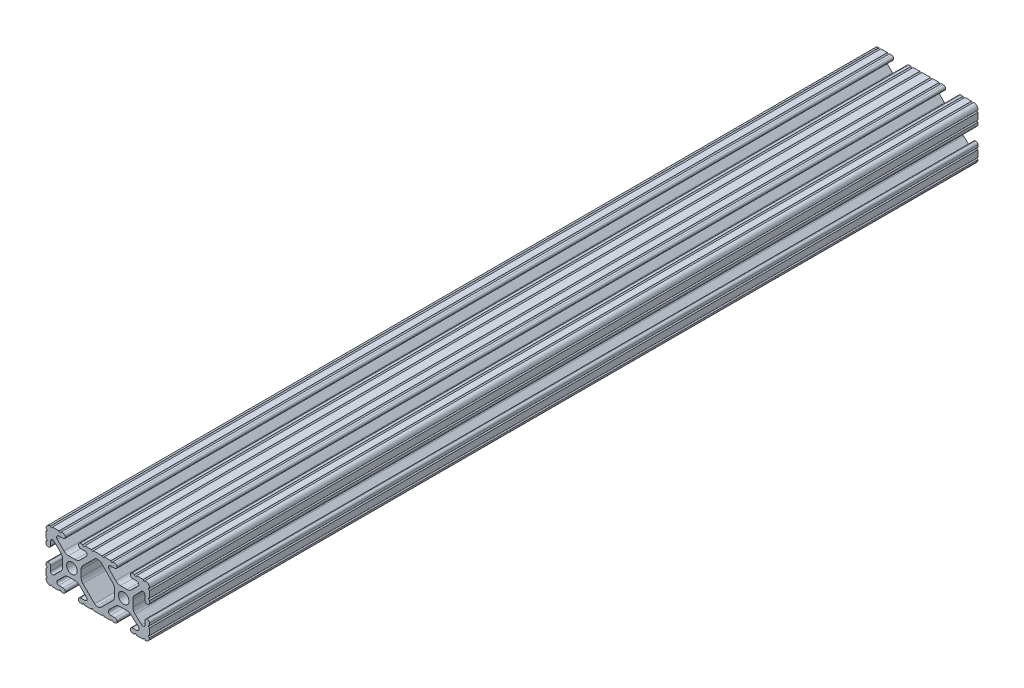
from build123d import *

# Parameters (mm, degrees)
SKETCH1_R           = 2.6035
BOSS_EXTRUDE1_DEPTH = 203.2


with BuildPart() as part:
    # Sketch1 → Boss-Extrude1 (new body, symmetric)
    with BuildSketch(Plane.XY):
        with BuildLine():
            Line((18.01710265, 12.7), (16.98745015, 12.7))
            ThreePointArc((16.98745015, 12.7), (16.245730386, 12.392769614), (15.9385, 11.65104985))
            Line((15.9385, 11.65104985), (15.9385, 11.53922))
            ThreePointArc((15.9385, 11.53922), (16.245750844, 10.797450844), (16.98752, 10.4902))
            Line((16.98752, 10.4902), (19.116384363, 10.4902))
            ThreePointArc((19.116384363, 10.4902), (20.052502933, 9.869096983), (19.844087081, 8.765172272))
            Line((19.844087081, 8.765172272), (16.618993479, 5.455112286))
            ThreePointArc((16.618993479, 5.455112286), (15.578994274, 4.745442459), (14.344932584, 4.4958))
            Line((14.344932584, 4.4958), (11.083317835, 4.4958))
            ThreePointArc((11.083317835, 4.4958), (9.854330953, 4.743306833), (8.816955189, 5.447238587))
            Line((8.816955189, 5.447238587), (5.564154119, 8.762652677))
            ThreePointArc((5.564154119, 8.762652677), (5.352591412, 9.867473037), (6.289393385, 10.4902))
            Line((6.289393385, 10.4902), (8.41248, 10.4902))
            ThreePointArc((8.41248, 10.4902), (9.154249156, 10.797450844), (9.4615, 11.53922))
            Line((9.4615, 11.53922), (9.4615, 11.65104985))
            ThreePointArc((9.4615, 11.65104985), (9.154269614, 12.392769614), (8.41254985, 12.7))
            Line((8.41254985, 12.7), (7.38288465, 12.7))
            ThreePointArc((7.38288465, 12.7), (6.87488465, 12.192), (6.36688465, 12.7))
            Line((6.36688465, 12.7), (3.14958095, 12.7))
            ThreePointArc((3.14958095, 12.7), (2.64158095, 12.192), (2.13358095, 12.7))
            Line((2.13358095, 12.7), (-2.13358095, 12.7))
            ThreePointArc((-2.13358095, 12.7), (-2.64158095, 12.192), (-3.14958095, 12.7))
            Line((-3.14958095, 12.7), (-6.36689735, 12.7))
            ThreePointArc((-6.36689735, 12.7), (-6.87489735, 12.192), (-7.38289735, 12.7))
            Line((-7.38289735, 12.7), (-8.41254985, 12.7))
            ThreePointArc((-8.41254985, 12.7), (-9.154269614, 12.392769614), (-9.4615, 11.65104985))
            Line((-9.4615, 11.65104985), (-9.4615, 11.53922))
            ThreePointArc((-9.4615, 11.53922), (-9.154249156, 10.797450844), (-8.41248, 10.4902))
            Line((-8.41248, 10.4902), (-6.283641037, 10.4902))
            ThreePointArc((-6.283641037, 10.4902), (-5.297291557, 9.829633109), (-5.532576693, 8.666071843))
            Line((-5.532576693, 8.666071843), (-8.809985098, 5.416263103))
            ThreePointArc((-8.809985098, 5.416263103), (-9.836720513, 4.734920264), (-11.045536121, 4.4958))
            Line((-11.045536121, 4.4958), (-14.354463879, 4.4958))
            ThreePointArc((-14.354463879, 4.4958), (-15.563279487, 4.734920264), (-16.590014902, 5.416263103))
            Line((-16.590014902, 5.416263103), (-19.867423307, 8.666071843))
            ThreePointArc((-19.867423307, 8.666071843), (-20.102708443, 9.829633109), (-19.116358963, 10.4902))
            Line((-19.116358963, 10.4902), (-16.98752, 10.4902))
            ThreePointArc((-16.98752, 10.4902), (-16.245750844, 10.797450844), (-15.9385, 11.53922))
            Line((-15.9385, 11.53922), (-15.9385, 11.65104985))
            ThreePointArc((-15.9385, 11.65104985), (-16.245730386, 12.392769614), (-16.98745015, 12.7))
            Line((-16.98745015, 12.7), (-18.01711535, 12.7))
            ThreePointArc((-18.01711535, 12.7), (-18.52511535, 12.192), (-19.03311535, 12.7))
            Line((-19.03311535, 12.7), (-22.2504, 12.7))
            ThreePointArc((-22.2504, 12.7), (-22.758323491, 12.192000006), (-23.266399977, 12.699846982))
            ThreePointArc((-23.266399977, 12.699846982), (-24.782522516, 12.082522516), (-25.399846982, 10.566399977))
            ThreePointArc((-25.399846982, 10.566399977), (-24.892000006, 10.058323491), (-25.4, 9.5504))
            Line((-25.4, 9.5504), (-25.4, 6.3330836))
            ThreePointArc((-25.4, 6.3330836), (-24.892, 5.8250836), (-25.4, 5.3170836))
            Line((-25.4, 5.3170836), (-25.4, 4.237520184))
            ThreePointArc((-25.4, 4.237520184), (-25.107393763, 3.531106237), (-24.400979816, 3.2385))
            Line((-24.400979816, 3.2385), (-24.23922, 3.2385))
            ThreePointArc((-24.23922, 3.2385), (-23.497450844, 3.545750844), (-23.1902, 4.28752))
            Line((-23.1902, 4.28752), (-23.1902, 6.334741132))
            ThreePointArc((-23.1902, 6.334741132), (-22.556026952, 7.286023527), (-21.434002553, 7.066535717))
            Line((-21.434002553, 7.066535717), (-18.147950853, 3.808156468))
            ThreePointArc((-18.147950853, 3.808156468), (-17.452759693, 2.774838327), (-17.208501877, 1.553619571))
            Line((-17.208501877, 1.553619571), (-17.208501877, -1.695179196))
            ThreePointArc((-17.208501877, -1.695179196), (-17.450738657, -2.911536421), (-18.140486065, -3.942289578))
            Line((-18.140486065, -3.942289578), (-21.431579576, -7.227386226))
            ThreePointArc((-21.431579576, -7.227386226), (-22.55444896, -7.449940594), (-23.1902, -6.498002195))
            Line((-23.1902, -6.498002195), (-23.1902, -4.28752))
            ThreePointArc((-23.1902, -4.28752), (-23.497450844, -3.545750844), (-24.23922, -3.2385))
            Line((-24.23922, -3.2385), (-24.35098, -3.2385))
            ThreePointArc((-24.35098, -3.2385), (-25.092749156, -3.545750844), (-25.4, -4.28752))
            Line((-25.4, -4.28752), (-25.4, -5.3171344))
            ThreePointArc((-25.4, -5.3171344), (-24.892, -5.8251344), (-25.4, -6.3331344))
            Line((-25.4, -6.3331344), (-25.4, -9.5504))
            ThreePointArc((-25.4, -9.5504), (-24.892000006, -10.058323491), (-25.399846982, -10.566399977))
            ThreePointArc((-25.399846982, -10.566399977), (-24.782522516, -12.082522516), (-23.266399977, -12.699846982))
            ThreePointArc((-23.266399977, -12.699846982), (-22.758323491, -12.192000006), (-22.2504, -12.7))
            Line((-22.2504, -12.7), (-19.03308995, -12.7))
            ThreePointArc((-19.03308995, -12.7), (-18.52508995, -12.192), (-18.01708995, -12.7))
            Line((-18.01708995, -12.7), (-16.9874692, -12.7))
            ThreePointArc((-16.9874692, -12.7), (-16.245700044, -12.392749156), (-15.9384492, -11.65098))
            Line((-15.9384492, -11.65098), (-15.9384492, -11.53922))
            ThreePointArc((-15.9384492, -11.53922), (-16.245700044, -10.797450844), (-16.9874692, -10.4902))
            Line((-16.9874692, -10.4902), (-19.116358963, -10.4902))
            ThreePointArc((-19.116358963, -10.4902), (-20.055197748, -9.862578342), (-19.834124023, -8.755124678))
            Line((-19.834124023, -8.755124678), (-16.49660751, -5.423689618))
            ThreePointArc((-16.49660751, -5.423689618), (-15.467274017, -4.736928798), (-14.253591699, -4.4958))
            Line((-14.253591699, -4.4958), (-11.146408301, -4.4958))
            ThreePointArc((-11.146408301, -4.4958), (-9.932725983, -4.736928798), (-8.90339249, -5.423689618))
            Line((-8.90339249, -5.423689618), (-5.565875977, -8.755124678))
            ThreePointArc((-5.565875977, -8.755124678), (-5.344802252, -9.862578342), (-6.283641037, -10.4902))
            Line((-6.283641037, -10.4902), (-8.4125308, -10.4902))
            ThreePointArc((-8.4125308, -10.4902), (-9.154299956, -10.797450844), (-9.4615508, -11.53922))
            Line((-9.4615508, -11.53922), (-9.4615508, -11.65098))
            ThreePointArc((-9.4615508, -11.65098), (-9.154299956, -12.392749156), (-8.4125308, -12.7))
            Line((-8.4125308, -12.7), (-7.38287195, -12.7))
            ThreePointArc((-7.38287195, -12.7), (-6.87487195, -12.192), (-6.36687195, -12.7))
            Line((-6.36687195, -12.7), (-3.14960635, -12.7))
            ThreePointArc((-3.14960635, -12.7), (-2.64160635, -12.192), (-2.13360635, -12.7))
            Line((-2.13360635, -12.7), (2.13360635, -12.7))
            ThreePointArc((2.13360635, -12.7), (2.64159365, -12.1920127), (3.14958095, -12.7))
            Line((3.14958095, -12.7), (6.36691005, -12.7))
            ThreePointArc((6.36691005, -12.7), (6.87491005, -12.192), (7.38291005, -12.7))
            Line((7.38291005, -12.7), (8.4125308, -12.7))
            ThreePointArc((8.4125308, -12.7), (9.154299956, -12.392749156), (9.4615508, -11.65098))
            Line((9.4615508, -11.65098), (9.4615508, -11.53922))
            ThreePointArc((9.4615508, -11.53922), (9.154299956, -10.797450844), (8.4125308, -10.4902))
            Line((8.4125308, -10.4902), (6.289393385, -10.4902))
            ThreePointArc((6.289393385, -10.4902), (5.231590322, -9.783049717), (5.480677245, -8.535265862))
            Line((5.480677245, -8.535265862), (8.597933595, -5.423689618))
            ThreePointArc((8.597933595, -5.423689618), (9.627267088, -4.736928798), (10.840949406, -4.4958))
            Line((10.840949406, -4.4958), (14.102564155, -4.4958))
            ThreePointArc((14.102564155, -4.4958), (15.215927525, -4.697410182), (16.187895372, -5.276636531))
            Line((16.187895372, -5.276636531), (19.868247549, -8.482246082))
            ThreePointArc((19.868247549, -8.482246082), (20.188435806, -9.746879864), (19.116384363, -10.4902))
            Line((19.116384363, -10.4902), (16.9874692, -10.4902))
            ThreePointArc((16.9874692, -10.4902), (16.245700044, -10.797450844), (15.9384492, -11.53922))
            Line((15.9384492, -11.53922), (15.9384492, -11.65098))
            ThreePointArc((15.9384492, -11.65098), (16.245700044, -12.392749156), (16.9874692, -12.7))
            Line((16.9874692, -12.7), (18.01710265, -12.7))
            ThreePointArc((18.01710265, -12.7), (18.52510265, -12.192), (19.03310265, -12.7))
            Line((19.03310265, -12.7), (22.2504, -12.7))
            ThreePointArc((22.2504, -12.7), (22.758323491, -12.192000006), (23.266399977, -12.699846982))
            ThreePointArc((23.266399977, -12.699846982), (24.782522516, -12.082522516), (25.399846982, -10.566399977))
            ThreePointArc((25.399846982, -10.566399977), (24.892000006, -10.058323492), (25.4, -9.550400001))
            Line((25.4, -9.550400001), (25.4, -6.333083592))
            ThreePointArc((25.4, -6.333083592), (24.892000001, -5.825083593), (25.4, -5.317083593))
            Line((25.4, -5.317083593), (25.4, -4.237520184))
            ThreePointArc((25.4, -4.237520184), (25.107393763, -3.531106237), (24.400979816, -3.2385))
            Line((24.400979816, -3.2385), (24.189220184, -3.2385))
            ThreePointArc((24.189220184, -3.2385), (23.482806237, -3.531106237), (23.1902, -4.237520184))
            Line((23.1902, -4.237520184), (23.1902, -6.155876159))
            ThreePointArc((23.1902, -6.155876159), (22.62232736, -7.038258539), (21.583974541, -6.886926384))
            Line((21.583974541, -6.886926384), (18.29817066, -4.024970844))
            ThreePointArc((18.29817066, -4.024970844), (17.493730985, -2.946044689), (17.208501877, -1.630807374))
            Line((17.208501877, -1.630807374), (17.208501877, 1.630807374))
            ThreePointArc((17.208501877, 1.630807374), (17.442348332, 2.82673414), (18.109440981, 3.846495088))
            Line((18.109440981, 3.846495088), (21.526346532, 7.353420386))
            ThreePointArc((21.526346532, 7.353420386), (22.585896263, 7.574939077), (23.1902, 6.676867167))
            Line((23.1902, 6.676867167), (23.1902, 4.237520184))
            ThreePointArc((23.1902, 4.237520184), (23.482806237, 3.531106237), (24.189220184, 3.2385))
            Line((24.189220184, 3.2385), (24.400979816, 3.2385))
            ThreePointArc((24.400979816, 3.2385), (25.107393763, 3.531106237), (25.4, 4.237520184))
            Line((25.4, 4.237520184), (25.4, 5.3170836))
            ThreePointArc((25.4, 5.3170836), (24.891949193, 5.825134407), (25.4, 6.333185215))
            Line((25.4, 6.333185215), (25.4, 9.550400015))
            ThreePointArc((25.4, 9.550400015), (24.892000013, 10.058323498), (25.399846982, 10.566399977))
            ThreePointArc((25.399846982, 10.566399977), (24.782522516, 12.082522516), (23.266399977, 12.699846982))
            ThreePointArc((23.266399977, 12.699846982), (22.758323491, 12.192000006), (22.2504, 12.7))
            Line((22.2504, 12.7), (19.03310265, 12.7))
            ThreePointArc((19.03310265, 12.7), (18.52510265, 12.192), (18.01710265, 12.7))
        make_face()
        with Locations((-12.7, 0)):
            Circle(SKETCH1_R, mode=Mode.SUBTRACT)
        with Locations((12.7, 0)):
            Circle(SKETCH1_R, mode=Mode.SUBTRACT)
        with BuildLine():
            Line((-7.259513935, -3.869413038), (-1.545748891, -9.572766749))
            ThreePointArc((-1.545748891, -9.572766749), (-1.035199478, -9.913400116), (-0.433213048, -10.033))
            Line((-0.433213048, -10.033), (0.433213048, -10.033))
            ThreePointArc((0.433213048, -10.033), (1.035199478, -9.913400116), (1.545748891, -9.572766749))
            Line((1.545748891, -9.572766749), (7.259513935, -3.869413038))
            ThreePointArc((7.259513935, -3.869413038), (7.949261343, -2.838659881), (8.191498123, -1.622302656))
            Line((8.191498123, -1.622302656), (8.191498123, 1.622302656))
            ThreePointArc((8.191498123, 1.622302656), (7.955573352, 2.823327967), (7.282860769, 3.845864069))
            Line((7.282860769, 3.845864069), (1.675572808, 9.561086461))
            ThreePointArc((1.675572808, 9.561086461), (1.161034429, 9.910236611), (0.551456936, 10.033))
            Line((0.551456936, 10.033), (-0.395199982, 10.033))
            ThreePointArc((-0.395199982, 10.033), (-0.994772524, 9.914396349), (-1.50403329, 9.576450301))
            Line((-1.50403329, 9.576450301), (-7.252049147, 3.876839553))
            ThreePointArc((-7.252049147, 3.876839553), (-7.947240307, 2.843521412), (-8.191498123, 1.622302656))
            Line((-8.191498123, 1.622302656), (-8.191498123, -1.622302656))
            ThreePointArc((-8.191498123, -1.622302656), (-7.949261343, -2.838659881), (-7.259513935, -3.869413038))
        make_face(mode=Mode.SUBTRACT)
    extrude(amount=BOSS_EXTRUDE1_DEPTH, both=True)


solid = part.part
